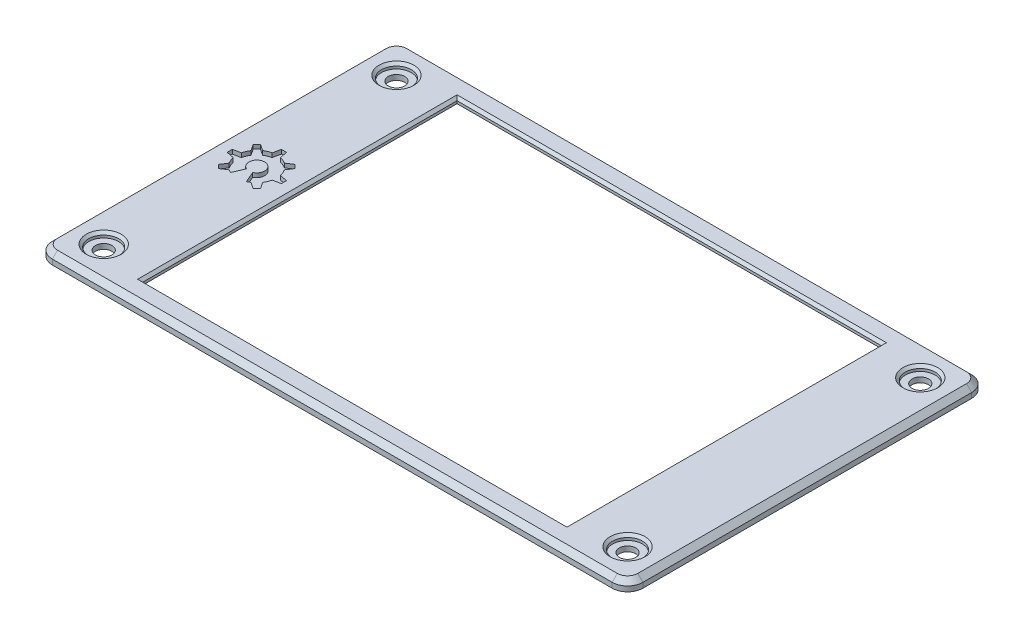
from build123d import *

# Parameters (mm, degrees)
SKETCH1_R           = 1.6
SKETCH1_W           = 82.6
SKETCH1_H           = 61.2
BOSS_EXTRUDE1_DEPTH = 2
SKETCH2_W           = 84.6
SKETCH2_H           = 63.2
CUT_EXTRUDE1_DEPTH  = 1
CHAMFER1_SIZE       = 0.5
SKETCH3_R           = 2.9
CUT_EXTRUDE2_DEPTH  = 1
CHAMFER2_SIZE       = 0.5
CHAMFER3_SIZE       = 1
CUT_EXTRUDE3_DEPTH  = 0.8


with BuildPart() as part:
    # Sketch1 → Boss-Extrude1 (new body)
    with BuildSketch(Plane(origin=(0, 0, 0), x_dir=(1, 0, 0), z_dir=(0, 1, 0))):
        with BuildLine():
            Line((3, 0), (112, 0))
            ThreePointArc((112, 0), (114.121320344, 0.878679656), (115, 3))
            Line((115, 3), (115, 67))
            ThreePointArc((115, 67), (114.121320344, 69.121320344), (112, 70))
            Line((112, 70), (3, 70))
            ThreePointArc((3, 70), (0.878679656, 69.121320344), (0, 67))
            Line((0, 67), (0, 3))
            ThreePointArc((0, 3), (0.878679656, 0.878679656), (3, 0))
        make_face()
        with Locations((6.5, 63.5)):
            Circle(SKETCH1_R, mode=Mode.SUBTRACT)
        with Locations((6.5, 6.5)):
            Circle(SKETCH1_R, mode=Mode.SUBTRACT)
        with Locations((108.5, 6.5)):
            Circle(SKETCH1_R, mode=Mode.SUBTRACT)
        with Locations((108.5, 63.5)):
            Circle(SKETCH1_R, mode=Mode.SUBTRACT)
        with Locations((57.5, 35)):
            Rectangle(SKETCH1_W, SKETCH1_H, mode=Mode.SUBTRACT)
    extrude(amount=BOSS_EXTRUDE1_DEPTH)

    # Sketch2 → Cut-Extrude1 (cut)
    with BuildSketch(Plane.XZ):
        with Locations((57.5, -35)):
            Rectangle(SKETCH2_W, SKETCH2_H)
    extrude(amount=-CUT_EXTRUDE1_DEPTH, mode=Mode.SUBTRACT)

    # Chamfer1
    chamfer1_edges = [part.edges().sort_by_distance(p)[0] for p in [
        (16.2, 2, -35),
        (57.5, 2, -4.4),
        (98.8, 2, -35),
        (57.5, 2, -65.6),
    ]]
    chamfer(chamfer1_edges, length=CHAMFER1_SIZE)

    # Sketch3 → Cut-Extrude2 (cut)
    with BuildSketch(Plane(origin=(0, 2, 0), x_dir=(1, 0, 0), z_dir=(0, 1, 0))):
        with Locations((6.5, 63.5)):
            Circle(SKETCH3_R)
        with Locations((108.5, 63.5)):
            Circle(SKETCH3_R)
        with Locations((108.5, 6.5)):
            Circle(SKETCH3_R)
        with Locations((6.5, 6.5)):
            Circle(SKETCH3_R)
    extrude(amount=-CUT_EXTRUDE2_DEPTH, mode=Mode.SUBTRACT)

    # Chamfer2
    chamfer2_edges = [part.edges().sort_by_distance(p)[0] for p in [
        (105.6, 2, -63.5),
        (3.6, 2, -63.5),
        (3.6, 2, -6.5),
        (105.6, 2, -6.5),
    ]]
    chamfer(chamfer2_edges, length=CHAMFER2_SIZE)

    # Chamfer3
    chamfer3_edges = [part.edges().sort_by_distance(p)[0] for p in [
        (114.121320344, 2, -0.878679656),
        (115, 2, -35),
        (114.121320344, 2, -69.121320344),
        (57.5, 2, -70),
        (0.878679656, 2, -69.121320344),
        (0, 2, -35),
        (0.878679656, 2, -0.878679656),
        (57.5, 2, 0),
    ]]
    chamfer(chamfer3_edges, length=CHAMFER3_SIZE)

    # Sketch4 → Cut-Extrude3 (cut)
    with BuildSketch(Plane(origin=(0, 2, 0), x_dir=(1, 0, 0), z_dir=(0, 1, 0))):
        with BuildLine():
            Line((9.825395701, 30.960299483), (8.89586377, 33.118648479))
            ThreePointArc((8.89586377, 33.118648479), (8.290679151, 36.053871442), (7.685494532, 33.118648479))
            Line((7.685494532, 33.118648479), (6.755962601, 30.960299483))
            ThreePointArc((6.755962601, 30.960299483), (6.457149652, 31.104431492), (6.171741697, 31.273563139))
            Line((6.171741697, 31.273563139), (4.91328092, 30.43936643))
            Line((4.91328092, 30.43936643), (4.55972753, 30.792919821))
            Line((4.55972753, 30.792919821), (4.206174139, 31.146473212))
            Line((4.206174139, 31.146473212), (5.040370847, 32.404933989))
            ThreePointArc((5.040370847, 32.404933989), (4.706026565, 33.039059725), (4.494049066, 33.723871442))
            Line((4.494049066, 33.723871442), (3.014316768, 34.023871442))
            Line((3.014316768, 34.023871442), (3.014316768, 34.523871442))
            Line((3.014316768, 34.523871442), (3.014316768, 35.023871442))
            Line((3.014316768, 35.023871442), (4.494049066, 35.323871442))
            ThreePointArc((4.494049066, 35.323871442), (4.706026565, 36.00868316), (5.040370847, 36.642808896))
            Line((5.040370847, 36.642808896), (4.206174139, 37.901269673))
            Line((4.206174139, 37.901269673), (4.55972753, 38.254823064))
            Line((4.55972753, 38.254823064), (4.91328092, 38.608376454))
            Line((4.91328092, 38.608376454), (6.171741697, 37.774179746))
            ThreePointArc((6.171741697, 37.774179746), (6.805867433, 38.108524028), (7.490679151, 38.320501527))
            Line((7.490679151, 38.320501527), (7.790679151, 39.800233826))
            Line((7.790679151, 39.800233826), (8.290679151, 39.800233826))
            Line((8.290679151, 39.800233826), (8.790679151, 39.800233826))
            Line((8.790679151, 39.800233826), (9.090679151, 38.320501527))
            ThreePointArc((9.090679151, 38.320501527), (9.775490868, 38.108524028), (10.409616604, 37.774179746))
            Line((10.409616604, 37.774179746), (11.668077381, 38.608376454))
            Line((11.668077381, 38.608376454), (12.021630772, 38.254823064))
            Line((12.021630772, 38.254823064), (12.375184163, 37.901269673))
            Line((12.375184163, 37.901269673), (11.540987454, 36.642808896))
            ThreePointArc((11.540987454, 36.642808896), (11.875331737, 36.00868316), (12.087309236, 35.323871442))
            Line((12.087309236, 35.323871442), (13.567041534, 35.023871442))
            Line((13.567041534, 35.023871442), (13.567041534, 34.523871442))
            Line((13.567041534, 34.523871442), (13.567041534, 34.023871442))
            Line((13.567041534, 34.023871442), (12.087309236, 33.723871442))
            ThreePointArc((12.087309236, 33.723871442), (11.875331737, 33.039059725), (11.540987454, 32.404933989))
            Line((11.540987454, 32.404933989), (12.375184163, 31.146473212))
            Line((12.375184163, 31.146473212), (12.021630772, 30.792919821))
            Line((12.021630772, 30.792919821), (11.668077381, 30.43936643))
            Line((11.668077381, 30.43936643), (10.409616604, 31.273563139))
            ThreePointArc((10.409616604, 31.273563139), (10.12420865, 31.104431492), (9.825395701, 30.960299483))
        make_face()
    extrude(amount=-CUT_EXTRUDE3_DEPTH, mode=Mode.SUBTRACT)


solid = part.part
